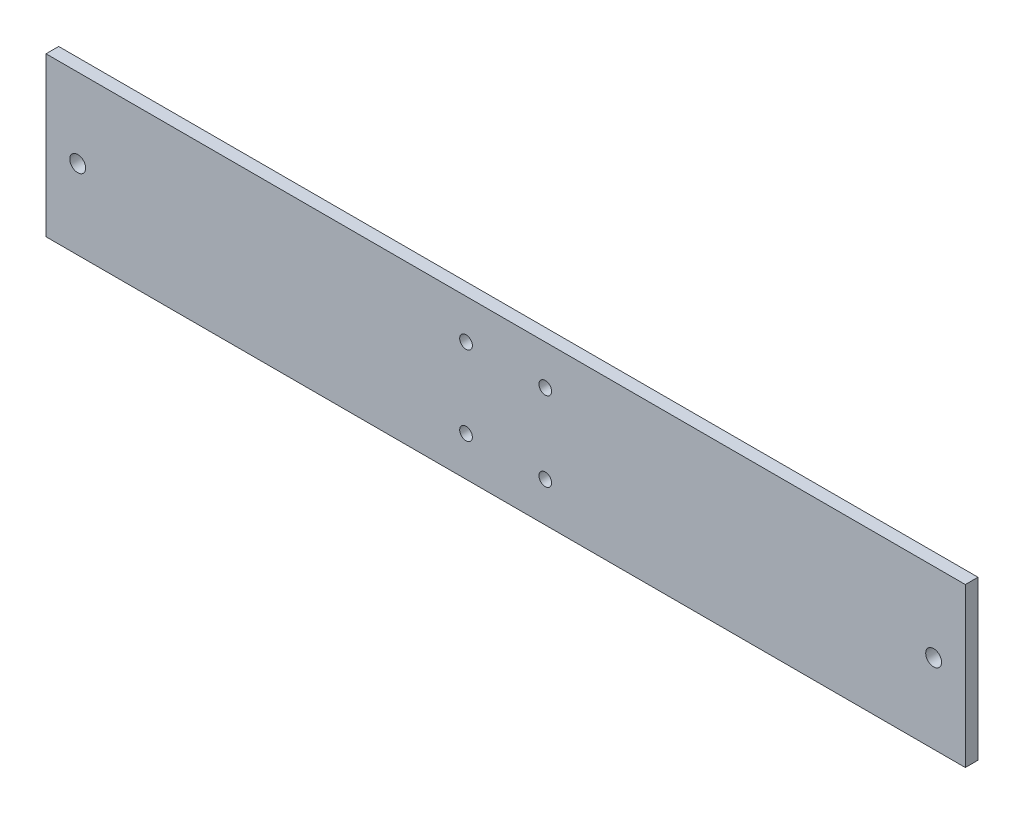
from build123d import *

# Parameters (mm, degrees)
SKETCH1_W           = 290
SKETCH1_H           = 50
SKETCH1_R           = 2
BOSS_EXTRUDE1_DEPTH = 4
SKETCH2_R           = 2.5
CUT_EXTRUDE1_DEPTH  = 4


with BuildPart() as part:
    # Sketch1 → Boss-Extrude1 (new body)
    with BuildSketch(Plane.XY):
        Rectangle(SKETCH1_W, SKETCH1_H)
        with Locations((-12.5, 12.5)):
            Circle(SKETCH1_R, mode=Mode.SUBTRACT)
        with Locations((12.5, 12.5)):
            Circle(SKETCH1_R, mode=Mode.SUBTRACT)
        with Locations((12.5, -12.5)):
            Circle(SKETCH1_R, mode=Mode.SUBTRACT)
        with Locations((-12.5, -12.5)):
            Circle(SKETCH1_R, mode=Mode.SUBTRACT)
    extrude(amount=BOSS_EXTRUDE1_DEPTH)

    # Sketch2 → Cut-Extrude1 (cut)
    with BuildSketch(Plane.XY.offset(4)):
        with Locations((-135, 0)):
            Circle(SKETCH2_R)
        with Locations((135, 0)):
            Circle(SKETCH2_R)
    extrude(amount=-CUT_EXTRUDE1_DEPTH, mode=Mode.SUBTRACT)


solid = part.part
